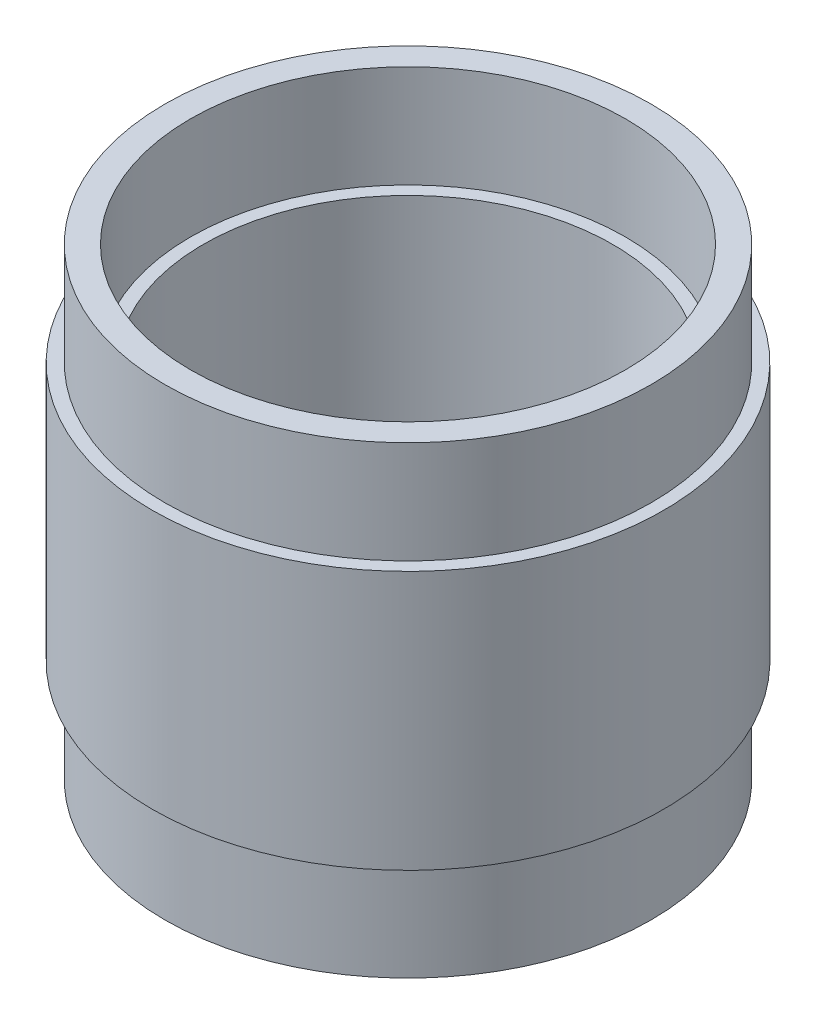
from build123d import *


with BuildPart() as part:
    # Sketch1 → Revolve1 (revolve)
    with BuildSketch(Plane.XY):
        Polygon((-60.325, 0), (-53.975, 0), (-53.975, 25.4), (-50.8, 25.4), (-50.8, 89.662), (-53.975, 89.662), (-53.975, 115.062), (-60.325, 115.062), (-60.325, 89.662), (-63.5, 89.662), (-63.5, 25.4), (-60.325, 25.4), align=None)
    revolve(axis=Axis((0, 132.254272853, 0), (0, -1, 0)))


solid = part.part
